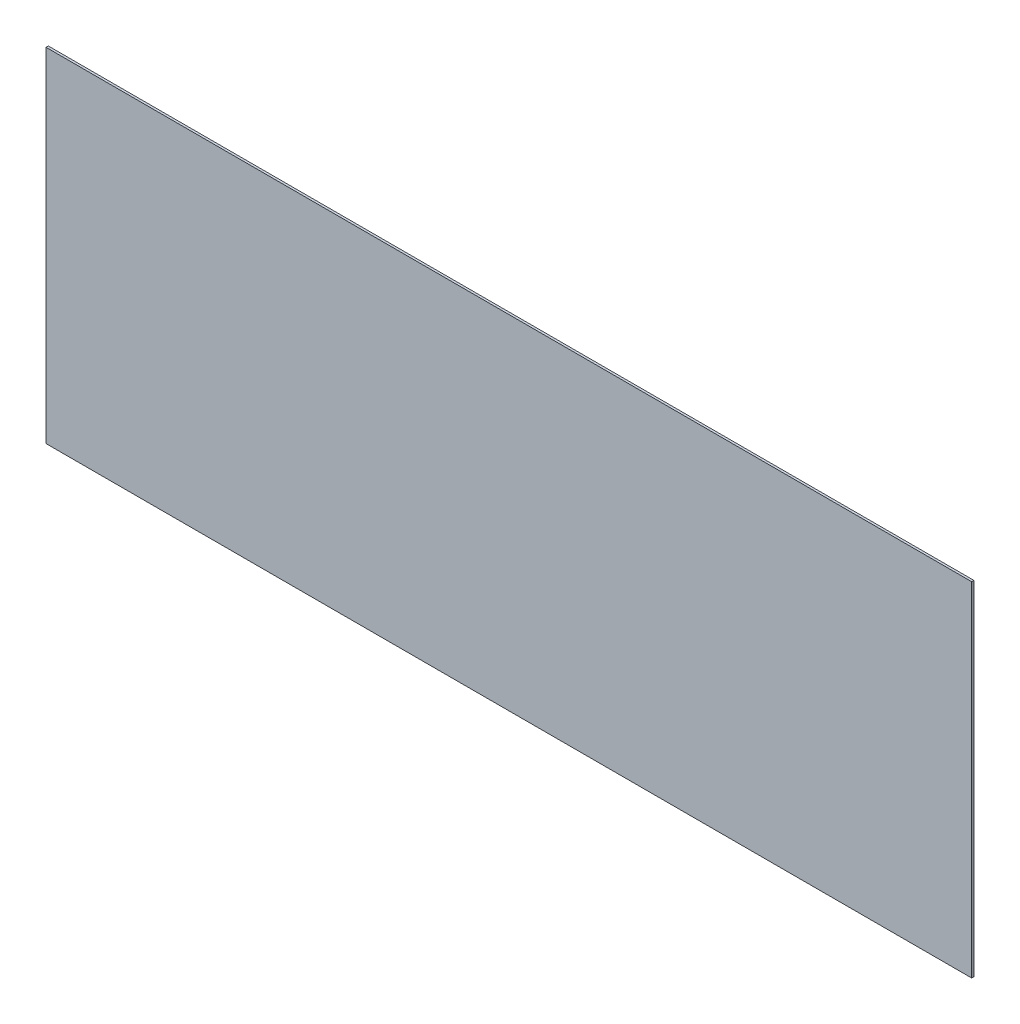
from build123d import *

# Parameters (mm, degrees)
SKETCH1_W           = 1219.2
SKETCH1_H           = 452.12
BOSS_EXTRUDE1_DEPTH = 2.9972


with BuildPart() as part:
    # Sketch1 → Boss-Extrude1 (new body)
    with BuildSketch(Plane.XY):
        Rectangle(SKETCH1_W, SKETCH1_H)
    extrude(amount=BOSS_EXTRUDE1_DEPTH)


solid = part.part
